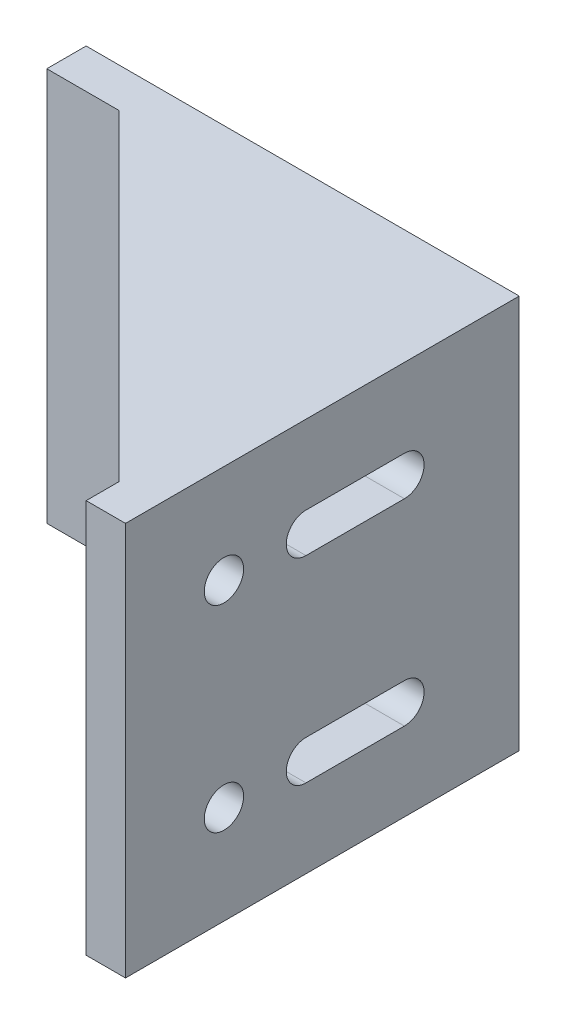
from build123d import *

# Parameters (mm, degrees)
SKETCH1_W           = 60
SKETCH1_H           = 60
SKETCH1_R           = 3
BOSS_EXTRUDE1_DEPTH = 6
SKETCH2_W           = 60
SKETCH2_H           = 60
SKETCH2_R           = 3
BOSS_EXTRUDE2_DEPTH = 6
BOSS_EXTRUDE3_DEPTH = 3
BOSS_EXTRUDE4_DEPTH = 3


with BuildPart() as part:
    # Sketch1 → Boss-Extrude1 (new body)
    with BuildSketch(Plane.XY):
        with Locations((30, 30)):
            Rectangle(SKETCH1_W, SKETCH1_H)
        with Locations((15, 45)):
            Circle(SKETCH1_R, mode=Mode.SUBTRACT)
        with Locations((15, 15)):
            Circle(SKETCH1_R, mode=Mode.SUBTRACT)
        with BuildLine():
            Line((27.5, 42), (42.5, 42))
            ThreePointArc((42.5, 42), (45.5, 45), (42.5, 48))
            Line((42.5, 48), (27.5, 48))
            ThreePointArc((27.5, 48), (24.5, 45), (27.5, 42))
        make_face(mode=Mode.SUBTRACT)
        with BuildLine():
            Line((27.5, 12), (42.5, 12))
            ThreePointArc((42.5, 12), (45.5, 15), (42.5, 18))
            Line((42.5, 18), (27.5, 18))
            ThreePointArc((27.5, 18), (24.5, 15), (27.5, 12))
        make_face(mode=Mode.SUBTRACT)
    extrude(amount=BOSS_EXTRUDE1_DEPTH)

    # Sketch2 → Boss-Extrude2 (add)
    with BuildSketch(Plane(origin=(60, 0, 0), x_dir=(0, 0, -1), z_dir=(1, 0, 0))):
        with Locations((-30, 30)):
            Rectangle(SKETCH2_W, SKETCH2_H)
        with Locations((-45, 45)):
            Circle(SKETCH2_R, mode=Mode.SUBTRACT)
        with Locations((-45, 15)):
            Circle(SKETCH2_R, mode=Mode.SUBTRACT)
        with BuildLine():
            Line((-32.5, 48), (-17.5, 48))
            ThreePointArc((-17.5, 48), (-14.5, 45), (-17.5, 42))
            Line((-17.5, 42), (-32.5, 42))
            ThreePointArc((-32.5, 42), (-35.5, 45), (-32.5, 48))
        make_face(mode=Mode.SUBTRACT)
        with BuildLine():
            Line((-32.5, 18), (-17.5, 18))
            ThreePointArc((-17.5, 18), (-14.5, 15), (-17.5, 12))
            Line((-17.5, 12), (-32.5, 12))
            ThreePointArc((-32.5, 12), (-35.5, 15), (-32.5, 18))
        make_face(mode=Mode.SUBTRACT)
    extrude(amount=BOSS_EXTRUDE2_DEPTH)

    # Sketch3 → Boss-Extrude3 (add)
    with BuildSketch(Plane(origin=(0, 60, 0), x_dir=(1, 0, 0), z_dir=(0, 1, 0))):
        Polygon((66, 0), (11, 0), (11, -6), (60, -55), (66, -55), align=None)
    extrude(amount=-BOSS_EXTRUDE3_DEPTH)

    # Sketch4 → Boss-Extrude4 (add)
    with BuildSketch(Plane.XZ):
        Polygon((66, 0), (66, 55), (60, 55), (11, 6), (11, 0), align=None)
    extrude(amount=-BOSS_EXTRUDE4_DEPTH)


solid = part.part
